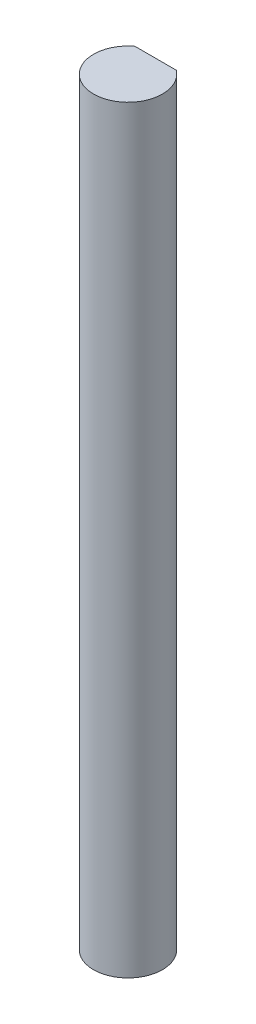
from build123d import *

# Parameters (mm, degrees)
BOSS_EXTRUDE1_DEPTH = 69.85


with BuildPart() as part:
    # Sketch1 → Boss-Extrude1 (new body)
    with BuildSketch(Plane(origin=(0, 0, 0), x_dir=(1, 0, 0), z_dir=(0, 1, 0))):
        with BuildLine():
            Line((-1.905, 2.54), (1.905, 2.54))
            ThreePointArc((1.905, 2.54), (0, -3.175), (-1.905, 2.54))
        make_face()
    extrude(amount=BOSS_EXTRUDE1_DEPTH)


solid = part.part
